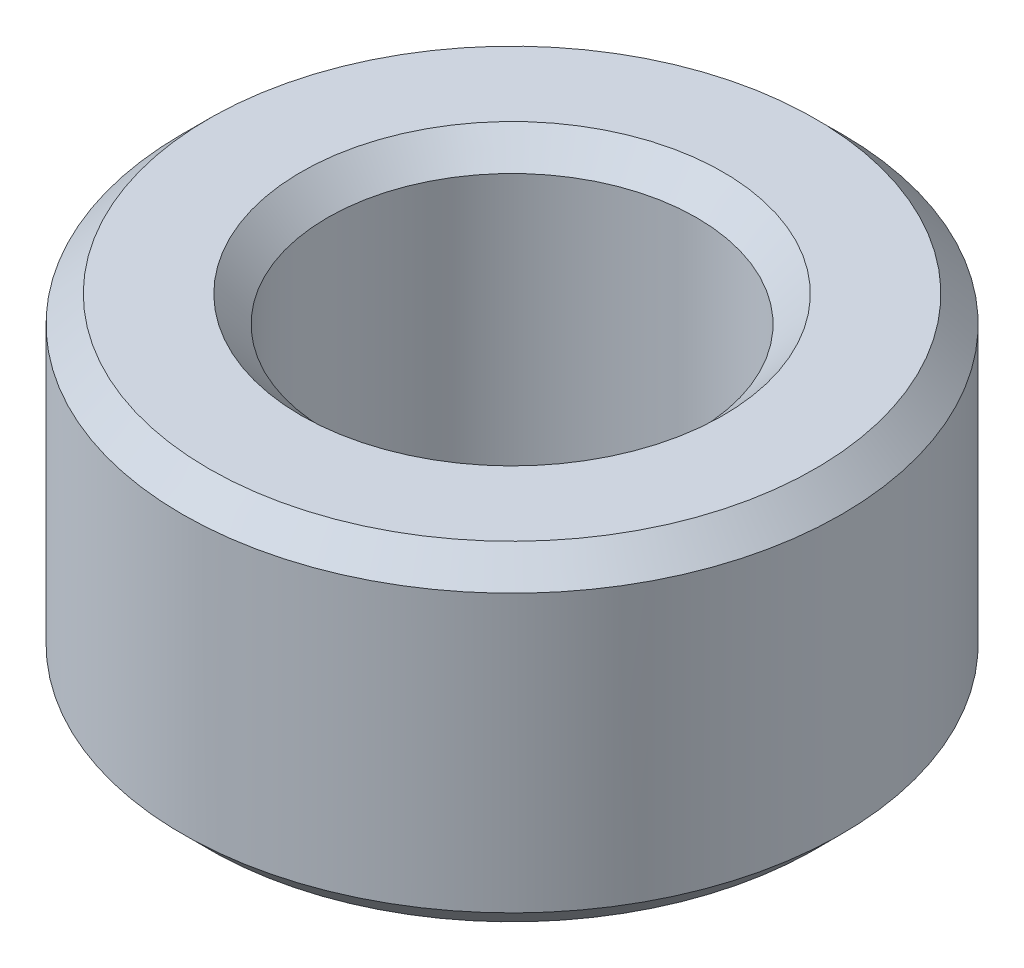
from build123d import *

# Parameters (mm, degrees)
SKETCH1_W     = 1.397
SKETCH1_H     = 3.175
CHAMFER1_SIZE = 0.254


with BuildPart() as part:
    # Sketch1 → Revolve1 (revolve)
    with BuildSketch(Plane.XY):
        with Locations((2.4765, 0)):
            Rectangle(SKETCH1_W, SKETCH1_H)
    revolve(axis=Axis((0, 0, 0), (0, 1, 0)))

    # Chamfer1
    chamfer1_edges = [part.edges().sort_by_distance(p)[0] for p in [
        (-1.778, -1.5875, 0),
        (-3.175, -1.5875, 0),
        (-3.175, 1.5875, 0),
        (-1.778, 1.5875, 0),
    ]]
    chamfer(chamfer1_edges, length=CHAMFER1_SIZE)


solid = part.part
